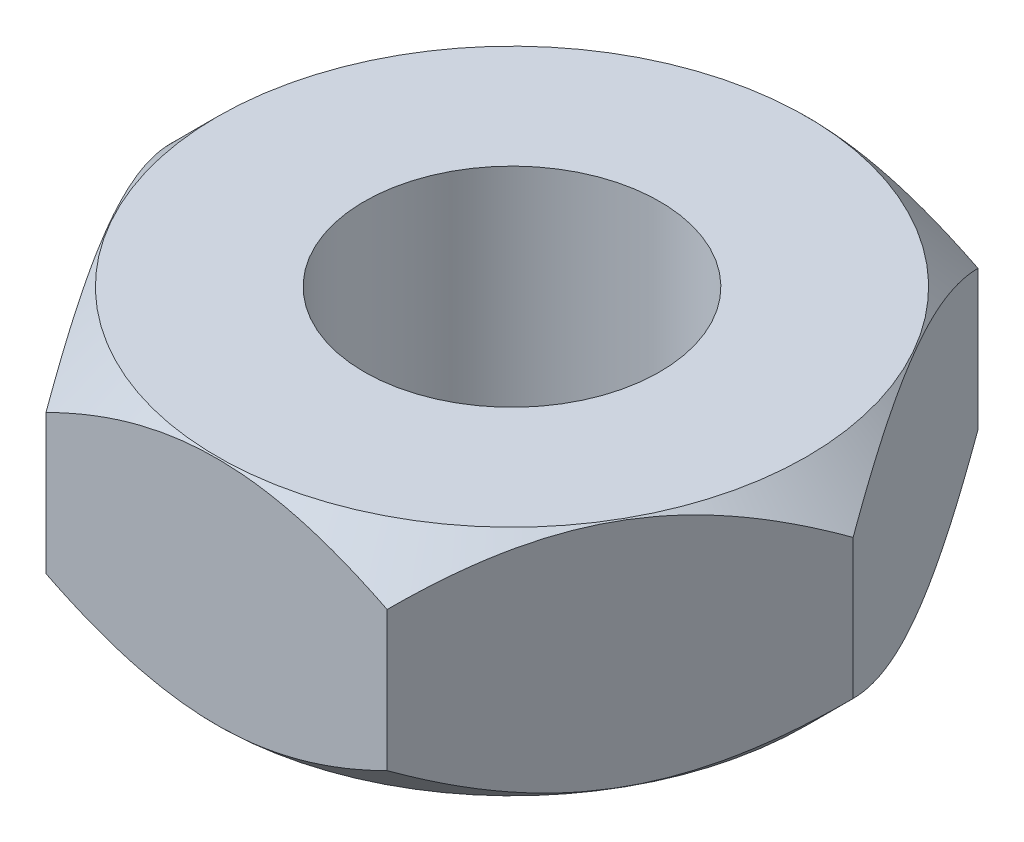
from build123d import *

# Parameters (mm, degrees)
CROQUIS1_R              = 6.35
SALIENTE_EXTRUIR1_DEPTH = 10


with BuildPart() as part:
    # Croquis1 → Saliente-Extruir1 (new body)
    with BuildSketch(Plane(origin=(0, 0, 0), x_dir=(1, 0, 0), z_dir=(0, 1, 0))):
        Polygon((-7.332348419, -12.7), (7.332348419, -12.7), (14.664696837, 0), (7.332348419, 12.7), (-7.332348419, 12.7), (-14.664696837, 0), align=None)
        Circle(CROQUIS1_R, mode=Mode.SUBTRACT)
    extrude(amount=SALIENTE_EXTRUIR1_DEPTH)

    # Croquis2 → Cortar-Revolución1 (revolve, cut)
    with BuildSketch(Plane.XY):
        Polygon((-14.664696837, 8), (-12.664696837, 10), (-14.664696837, 10), align=None)
    cortar_revoluci_n1 = revolve(axis=Axis((0, 0, 0), (0, 1, 0)), mode=Mode.SUBTRACT)

    # Simetría1: Cortar-Revolución1 across plane
    add(cortar_revoluci_n1.mirror(Plane.ZX.offset(5)), mode=Mode.SUBTRACT)


solid = part.part
